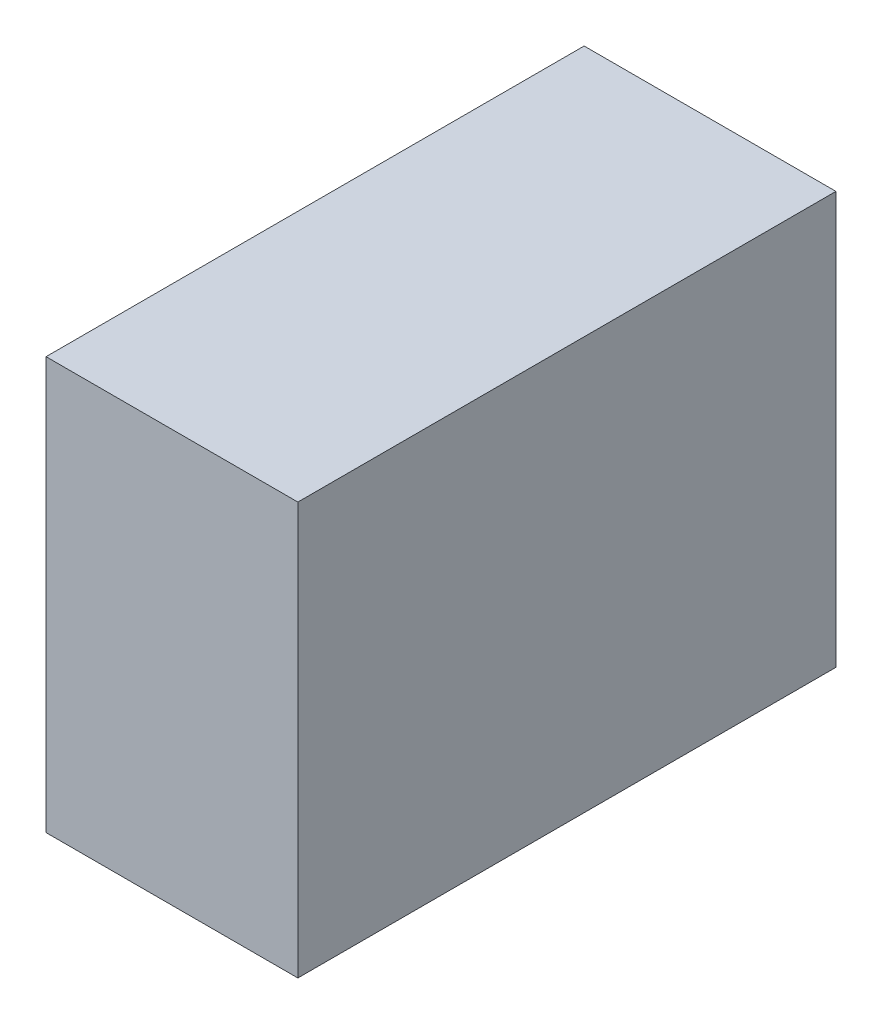
from build123d import *

# Parameters (mm, degrees)
SKETCH1_W           = 33.6
SKETCH1_H           = 55
BOSS_EXTRUDE1_DEPTH = 71.8


with BuildPart() as part:
    # Sketch1 → Boss-Extrude1 (new body)
    with BuildSketch(Plane.XY):
        with Locations((16.8, 27.5)):
            Rectangle(SKETCH1_W, SKETCH1_H)
    extrude(amount=BOSS_EXTRUDE1_DEPTH)


solid = part.part
